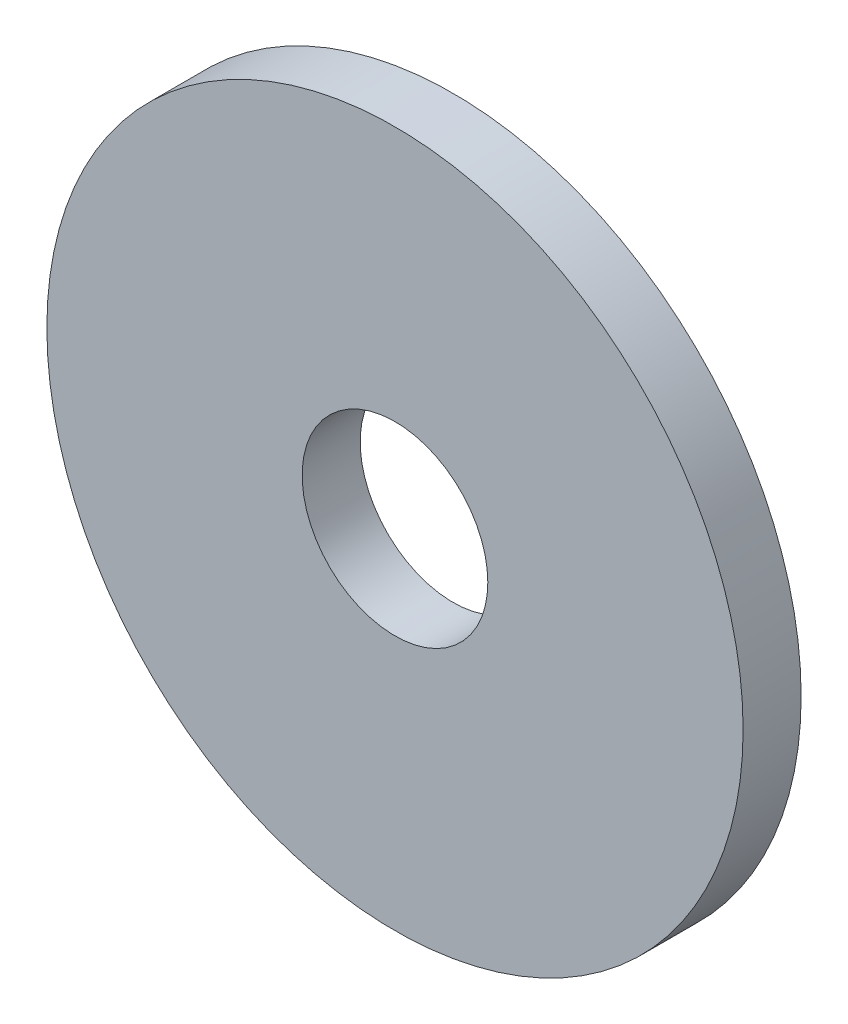
from build123d import *

# Parameters (mm, degrees)
SKETCH1_R           = 9.525
SKETCH1_R_2         = 2.54
BOSS_EXTRUDE1_DEPTH = 1.5875


with BuildPart() as part:
    # Sketch1 → Boss-Extrude1 (new body)
    with BuildSketch(Plane.XY):
        Circle(SKETCH1_R)
        Circle(SKETCH1_R_2, mode=Mode.SUBTRACT)
    extrude(amount=BOSS_EXTRUDE1_DEPTH)


solid = part.part
